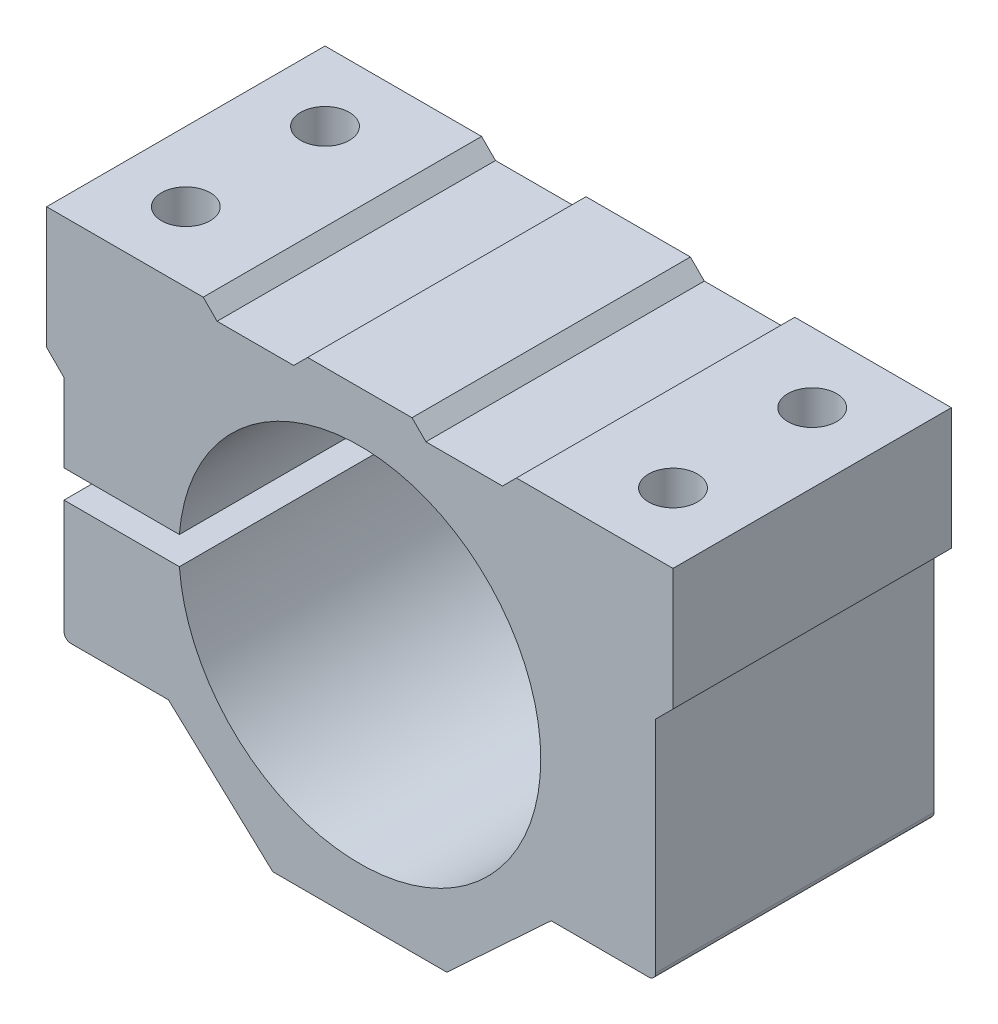
from build123d import *

# Parameters (mm, degrees)
SKETCH_1_R          = 26
EXTRUDE_1_DEPTH     = 40
SKETCH_2_R          = 3.5
CUT_EXTRUDE_1_DEPTH = 67.5
SKETCH_3_W          = 33.659947674
SKETCH_3_H          = 4
CUT_EXTRUDE_3_DEPTH = 41
FILLET_1_R          = 1


with BuildPart() as part:
    # 草图1 → 凸台-拉伸1 (new body)
    with BuildSketch(Plane.XY):
        Polygon((-12.5, -33.25), (12.5, -33.25), (27.5, -19.35), (42.5, -19.35), (42.5, 13.25), (45, 15.75), (45, 33.25), (22.5, 33.25), (20.5, 31.25), (9.5, 31.25), (7.5, 33.25), (-7.5, 33.25), (-9.5, 31.25), (-20.5, 31.25), (-22.5, 33.25), (-45, 33.25), (-45, 15.75), (-42.5, 13.25), (-42.5, -19.35), (-27.5, -19.35), align=None)
        Circle(SKETCH_1_R, mode=Mode.SUBTRACT)
    extrude(amount=EXTRUDE_1_DEPTH)

    # 草图2 → 切除-拉伸1 (cut, through all)
    with BuildSketch(Plane(origin=(0, 33.25, 0), x_dir=(1, 0, 0), z_dir=(0, 1, 0))):
        with Locations((-35, -10)):
            Circle(SKETCH_2_R)
        with Locations((-35, -30)):
            Circle(SKETCH_2_R)
        with Locations((35, -30)):
            Circle(SKETCH_2_R)
        with Locations((35, -10)):
            Circle(SKETCH_2_R)
    extrude(amount=-CUT_EXTRUDE_1_DEPTH, mode=Mode.SUBTRACT)

    # 草图3 → 切除-拉伸3 (cut, through all)
    with BuildSketch(Plane.XY):
        with Locations((-31.784741675, 0)):
            Rectangle(SKETCH_3_W, SKETCH_3_H)
    extrude(amount=CUT_EXTRUDE_3_DEPTH, mode=Mode.SUBTRACT)

    # 圆角1
    fillet_1_edges = [part.edges().sort_by_distance(p)[0] for p in [
        (42.5, -19.35, 20),
        (-42.5, -19.35, 20),
    ]]
    fillet(fillet_1_edges, radius=FILLET_1_R)


solid = part.part
